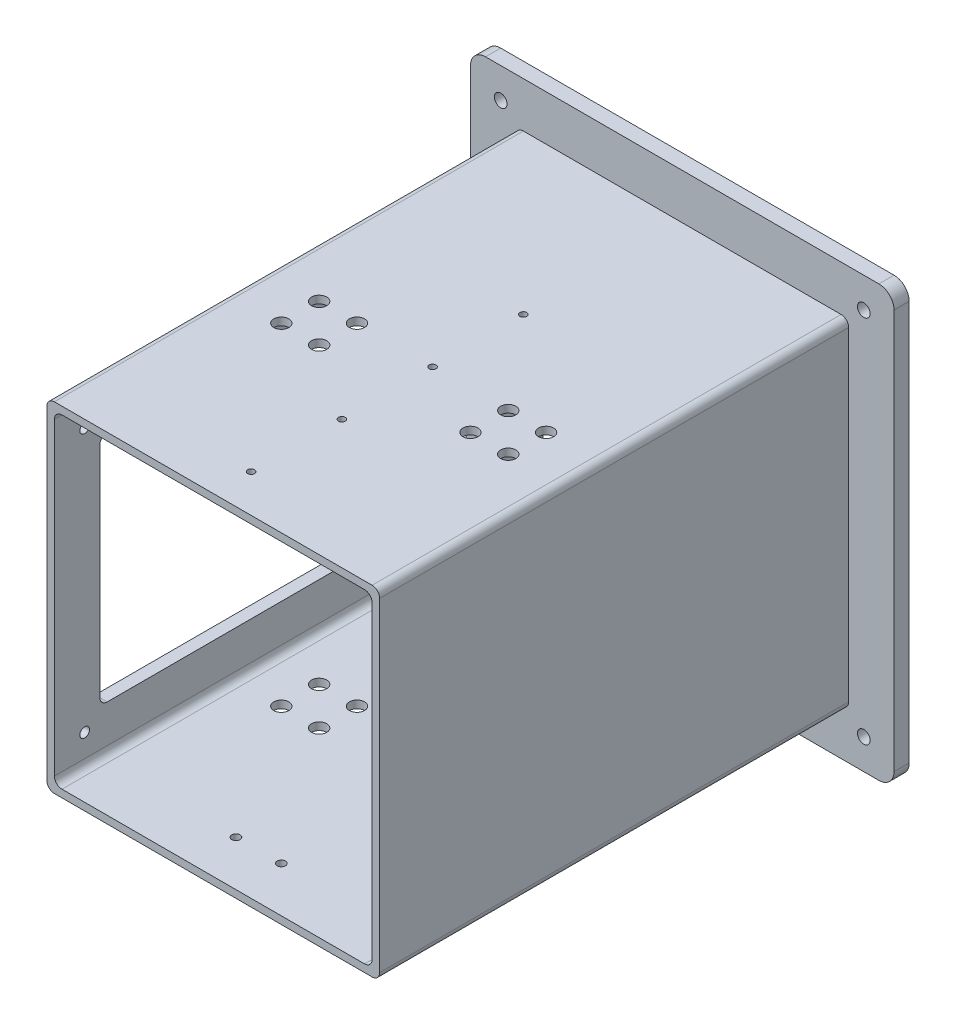
from build123d import *

# Parameters (mm, degrees)
SKETCH_1_W                  = 220
SKETCH_1_H                  = 224.25
SKETCH_1_W_2                = 210
SKETCH_1_H_2                = 214.25
EXTRUDE_1_DEPTH             = 310
SKETCH_2_W                  = 280
SKETCH_2_H                  = 284.25
SKETCH_2_W_2                = 210
SKETCH_2_H_2                = 214.25
EXTRUDE_2_DEPTH             = 10
FILLET_1_R                  = 5
FILLET_2_R                  = 5
FILLET_3_R                  = 10
HOLE_WIZARD_8_4_8_4_1_D     = 8.4
MM_11_D                     = 10
HOLE_WIZARD_4_5_4_5_1_D     = 4.5
HOLE_WIZARD_4_5_4_5_1_DEPTH = 5
HOLE_WIZARD_6_6_6_6_1_D     = 6.6
HOLE_WIZARD_6_6_6_6_1_DEPTH = 5
HOLE_WIZARD_5_5_5_5_1_D     = 5.5
HOLE_WIZARD_5_5_5_5_1_DEPTH = 5
CUT_EXTRUDE_1_REACH         = 252
SKETCH_45_W                 = 250
SKETCH_45_H                 = 154.25
FILLET_4_R                  = 5
SKETCH_49_W                 = 256
SKETCH_49_H                 = 160.25
EXTRUDE_3_DEPTH             = 3
FILLET_5_R                  = 5
SKETCH_50_W                 = 216
SKETCH_50_H                 = 220.25
EXTRUDE_4_DEPTH             = 3
FILLET_6_R                  = 5
HOLE_WIZARD_6_4_6_4_1_D     = 6.4
HOLE_WIZARD_6_4_6_4_1_DEPTH = 5
HOLE_WIZARD_4_2_4_2_1_D     = 4.2
HOLE_WIZARD_4_2_4_2_1_DEPTH = 5


with BuildPart() as part:
    # 草图1 → 凸台-拉伸1 (new body)
    with BuildSketch(Plane.XY):
        Rectangle(SKETCH_1_W, SKETCH_1_H)
        Rectangle(SKETCH_1_W_2, SKETCH_1_H_2, mode=Mode.SUBTRACT)
    extrude(amount=EXTRUDE_1_DEPTH)

    # 草图2 → 凸台-拉伸2 (add)
    with BuildSketch(Plane(origin=(0, 0, 0), x_dir=(-1, 0, 0), z_dir=(0, 0, -1))):
        Rectangle(SKETCH_2_W, SKETCH_2_H)
        Rectangle(SKETCH_2_W_2, SKETCH_2_H_2, mode=Mode.SUBTRACT)
    extrude(amount=EXTRUDE_2_DEPTH)

    # 圆角1
    fillet_1_edges = [part.edges().sort_by_distance(p)[0] for p in [
        (110, -112.125, 155),
        (-110, -112.125, 155),
        (-110, 112.125, 155),
        (110, 112.125, 155),
    ]]
    fillet(fillet_1_edges, radius=FILLET_1_R)

    # 圆角2
    fillet_2_edges = [part.edges().sort_by_distance(p)[0] for p in [
        (105, -107.125, 150),
        (105, 107.125, 150),
        (-105, 107.125, 150),
        (-105, -107.125, 150),
    ]]
    fillet(fillet_2_edges, radius=FILLET_2_R)

    # 圆角3
    fillet_3_edges = [part.edges().sort_by_distance(p)[0] for p in [
        (-140, -142.125, -5),
        (-140, 142.125, -5),
        (140, 142.125, -5),
        (140, -142.125, -5),
    ]]
    fillet(fillet_3_edges, radius=FILLET_3_R)

    # Ø8.4 (8.4) 直径孔1 (through all)
    with Locations(Plane.XY):
        with Locations((120, 122.125), (120, -122.125), (-120, -122.125), (-120, 122.125)):
            Hole(HOLE_WIZARD_8_4_8_4_1_D / 2)

    # 大小mm 暗销孔11 (through all)
    with Locations(Plane(origin=(0, 112.125, 0), x_dir=(1, 0, 0), z_dir=(0, 1, 0))):
        with Locations((-75, -165), (-50, -165), (-50, -190), (-75, -190), (50, -190), (50, -165), (75, -165), (75, -190)):
            Hole(MM_11_D / 2)

    # Ø4.5 (4.5) 直径孔1
    with Locations(Plane(origin=(0, 112.125, 0), x_dir=(1, 0, 0), z_dir=(0, 1, 0))):
        with Locations((0, -105), (0, -165), (0, -225), (0, -285)):
            Hole(HOLE_WIZARD_4_5_4_5_1_D / 2, depth=HOLE_WIZARD_4_5_4_5_1_DEPTH)

    # Ø6.6 (6.6) 直径孔1
    with Locations(Plane(origin=(0, -112.125, 0), x_dir=(-1, 0, 0), z_dir=(0, -1, 0))):
        with Locations((19, -105.5), (-19, -105.5)):
            Hole(HOLE_WIZARD_6_6_6_6_1_D / 2, depth=HOLE_WIZARD_6_6_6_6_1_DEPTH)

    # Ø5.5 (5.5) 直径孔1
    with Locations(Plane(origin=(0, -112.125, 0), x_dir=(-1, 0, 0), z_dir=(0, -1, 0))):
        with Locations((15, -280), (-15, -280)):
            Hole(HOLE_WIZARD_5_5_5_5_1_D / 2, depth=HOLE_WIZARD_5_5_5_5_1_DEPTH)

    # 草图45 → 切除-拉伸1 (cut, up to next)
    with BuildSketch(Plane.ZY.offset(110), mode=Mode.PRIVATE) as cut_extrude_1_sk1:
        with Locations((155, 0)):
            Rectangle(SKETCH_45_W, SKETCH_45_H)
    cut_extrude_1_tool1 = extrude(cut_extrude_1_sk1.sketch, amount=-CUT_EXTRUDE_1_REACH, mode=Mode.PRIVATE) & part.part
    add(cut_extrude_1_tool1.solids().sort_by_distance((-110, 0, 155))[0], mode=Mode.SUBTRACT)

    # 圆角4
    fillet_4_edges = [part.edges().sort_by_distance(p)[0] for p in [
        (-107.5, -77.125, 280),
        (-107.5, 77.125, 280),
        (-107.5, 77.125, 30),
        (-107.5, -77.125, 30),
    ]]
    fillet(fillet_4_edges, radius=FILLET_4_R)

    # 草图49 → 凸台-拉伸3 (add)
    with BuildSketch(Plane.ZY.offset(110)):
        with Locations((155, 0)):
            Rectangle(SKETCH_49_W, SKETCH_49_H)
        with BuildLine():
            Line((280, -72.125), (280, 72.125))
            ThreePointArc((280, 72.125), (278.535533906, 75.660533906), (275, 77.125))
            Line((275, 77.125), (35, 77.125))
            ThreePointArc((35, 77.125), (31.464466094, 75.660533906), (30, 72.125))
            Line((30, 72.125), (30, -72.125))
            ThreePointArc((30, -72.125), (31.464466094, -75.660533906), (35, -77.125))
            Line((35, -77.125), (275, -77.125))
            ThreePointArc((275, -77.125), (278.535533906, -75.660533906), (280, -72.125))
        make_face(mode=Mode.SUBTRACT)
    extrude(amount=EXTRUDE_3_DEPTH)

    # 圆角5
    fillet_5_edges = [part.edges().sort_by_distance(p)[0] for p in [
        (-111.5, 80.125, 27),
        (-111.5, -80.125, 27),
        (-111.5, -80.125, 283),
        (-111.5, 80.125, 283),
    ]]
    fillet(fillet_5_edges, radius=FILLET_5_R)

    # 草图50 → 凸台-拉伸4 (add)
    with BuildSketch(Plane(origin=(0, 0, -10), x_dir=(-1, 0, 0), z_dir=(0, 0, -1))):
        Rectangle(SKETCH_50_W, SKETCH_50_H)
        with BuildLine():
            Line((-100, -107.125), (100, -107.125))
            ThreePointArc((100, -107.125), (103.535533906, -105.660533906), (105, -102.125))
            Line((105, -102.125), (105, 102.125))
            ThreePointArc((105, 102.125), (103.535533906, 105.660533906), (100, 107.125))
            Line((100, 107.125), (-100, 107.125))
            ThreePointArc((-100, 107.125), (-103.535533906, 105.660533906), (-105, 102.125))
            Line((-105, 102.125), (-105, -102.125))
            ThreePointArc((-105, -102.125), (-103.535533906, -105.660533906), (-100, -107.125))
        make_face(mode=Mode.SUBTRACT)
    extrude(amount=EXTRUDE_4_DEPTH)

    # 圆角6
    fillet_6_edges = [part.edges().sort_by_distance(p)[0] for p in [
        (108, 110.125, -11.5),
        (108, -110.125, -11.5),
        (-108, -110.125, -11.5),
        (-108, 110.125, -11.5),
    ]]
    fillet(fillet_6_edges, radius=FILLET_6_R)

    # Ø6.4 (6.4) 直径孔1
    with Locations(Plane.ZY.offset(110)):
        with Locations((20, 87.125), (20, -87.125), (290, -87.125), (290, 87.125)):
            Hole(HOLE_WIZARD_6_4_6_4_1_D / 2, depth=HOLE_WIZARD_6_4_6_4_1_DEPTH)

    # Ø4.2 (4.2) 直径孔1
    with Locations(Plane(origin=(0, -107.125, 0), x_dir=(1, 0, 0), z_dir=(0, 1, 0))):
        with Locations((-15, -11.55), (15, -11.55), (15, -41.55), (-15, -41.55)):
            Hole(HOLE_WIZARD_4_2_4_2_1_D / 2, depth=HOLE_WIZARD_4_2_4_2_1_DEPTH)


solid = part.part
